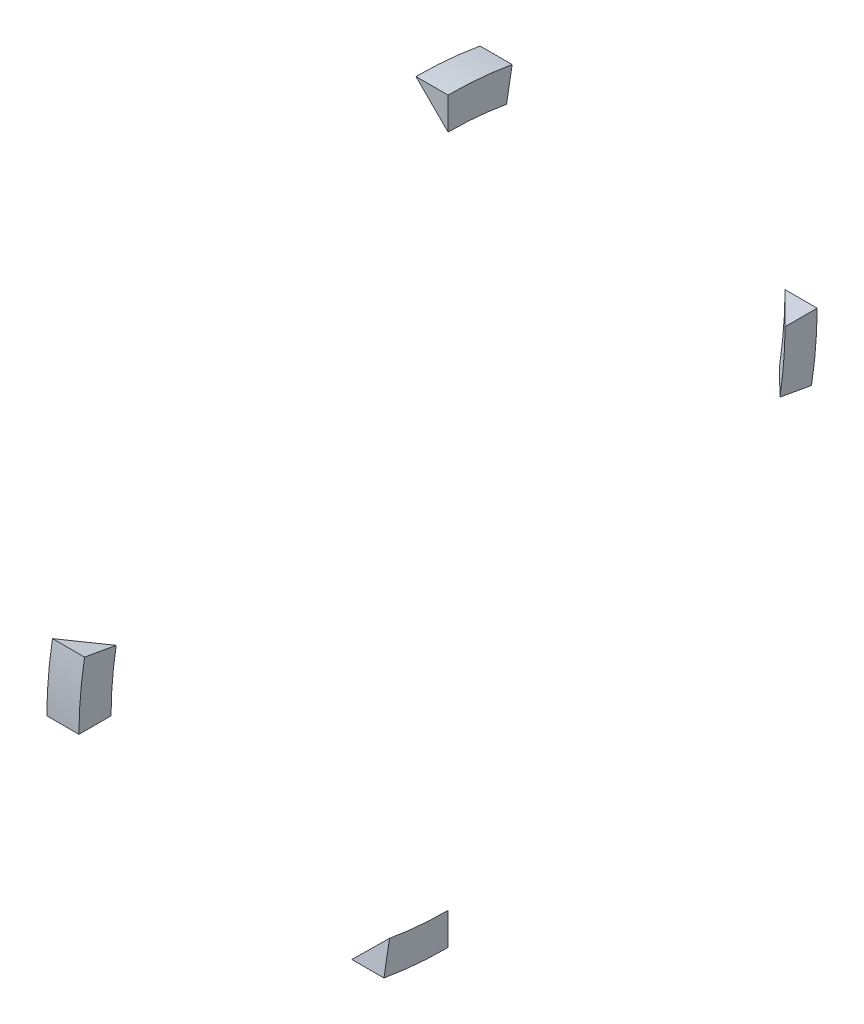
from build123d import *

# Parameters (mm, degrees)
REVOLVE1_ANGLE    = 10
CIRPATTERN1_COUNT = 4


with BuildPart() as part:
    # Sketch1 → Revolve1 (revolve)
    with BuildSketch(Plane.XY):
        Polygon((0, 0), (-12.7, 0), (0, -12.7), align=None)
    revolve(axis=Axis((0, -146.05, 0), (-1, 0, 0)), revolution_arc=REVOLVE1_ANGLE)


with BuildPart() as cirpattern1_1:
    # CirPattern1: pattern copy
    add(part.part.rotate(Axis((0, -146.05, 0), (-1, 0, 0)), 1 * 360 / CIRPATTERN1_COUNT))


with BuildPart() as cirpattern1_2:
    # CirPattern1: pattern copy
    add(part.part.rotate(Axis((0, -146.05, 0), (-1, 0, 0)), 2 * 360 / CIRPATTERN1_COUNT))


with BuildPart() as cirpattern1_3:
    # CirPattern1: pattern copy
    add(part.part.rotate(Axis((0, -146.05, 0), (-1, 0, 0)), 3 * 360 / CIRPATTERN1_COUNT))


solid = Compound([part.part, cirpattern1_1.part, cirpattern1_2.part, cirpattern1_3.part])
